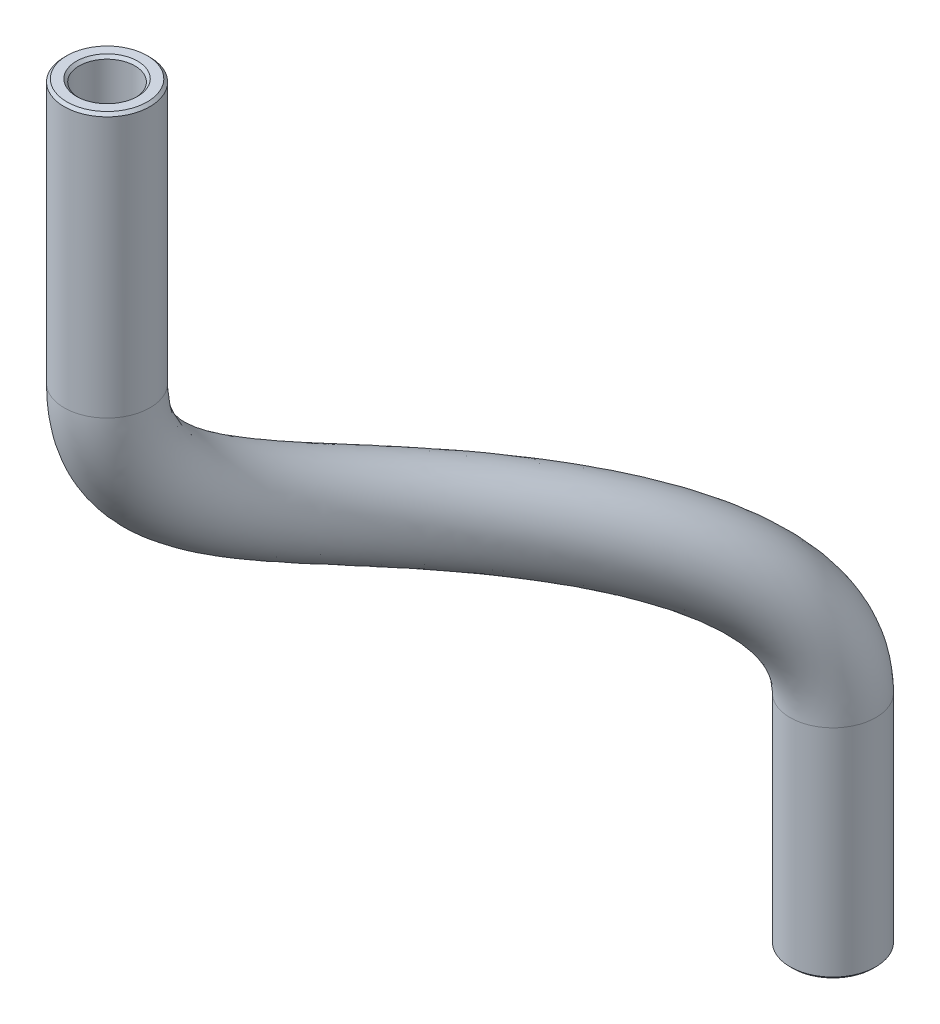
from build123d import *

# Parameters (mm, degrees)
SKETCH1_R     = 2
SKETCH1_R_2   = 1.3
CHAMFER1_SIZE = 0.127


with BuildPart() as part:
    # Sweep1: sweep along a curve in space
    with BuildLine() as sweep1_path:
        Line((83.325, -62.025, 13.85), (83.325, -74.325, 13.85))
        add(Edge.make_bspline(
            [(83.325, -74.325, 13.85), (83.325, -79.561648696, 13.85), (84.116451691, -83.759213783, 2.1625), (93.825, -87.829177017, -9.525), (93.825, -93.282256564, -9.525)],
            knots=[0, 0, 0, 0, 0.492860299, 1, 1, 1, 1], degree=3))
        Line((93.825, -103.482256564, -9.525), (93.825, -93.282256564, -9.525))
    # Sketch1 → Sweep1 (sweep)
    with BuildSketch(Plane(origin=(0, -95.382256564, 0), x_dir=(1, 0, 0), z_dir=(0, 1, 0))):
        with Locations((93.825, 9.525)):
            Circle(SKETCH1_R)
        with Locations((93.825, 9.525)):
            Circle(SKETCH1_R_2, mode=Mode.SUBTRACT)
    sweep(path=sweep1_path.line)

    # Chamfer1
    chamfer1_edges = [part.edges().sort_by_distance(p)[0] for p in [
        (92.525, -103.482256564, -9.525),
        (82.086225026, -62.025, 14.244254442),
        (91.825, -103.482256564, -9.525),
        (81.419192348, -62.025, 14.456545295),
    ]]
    chamfer(chamfer1_edges, length=CHAMFER1_SIZE)


solid = part.part
